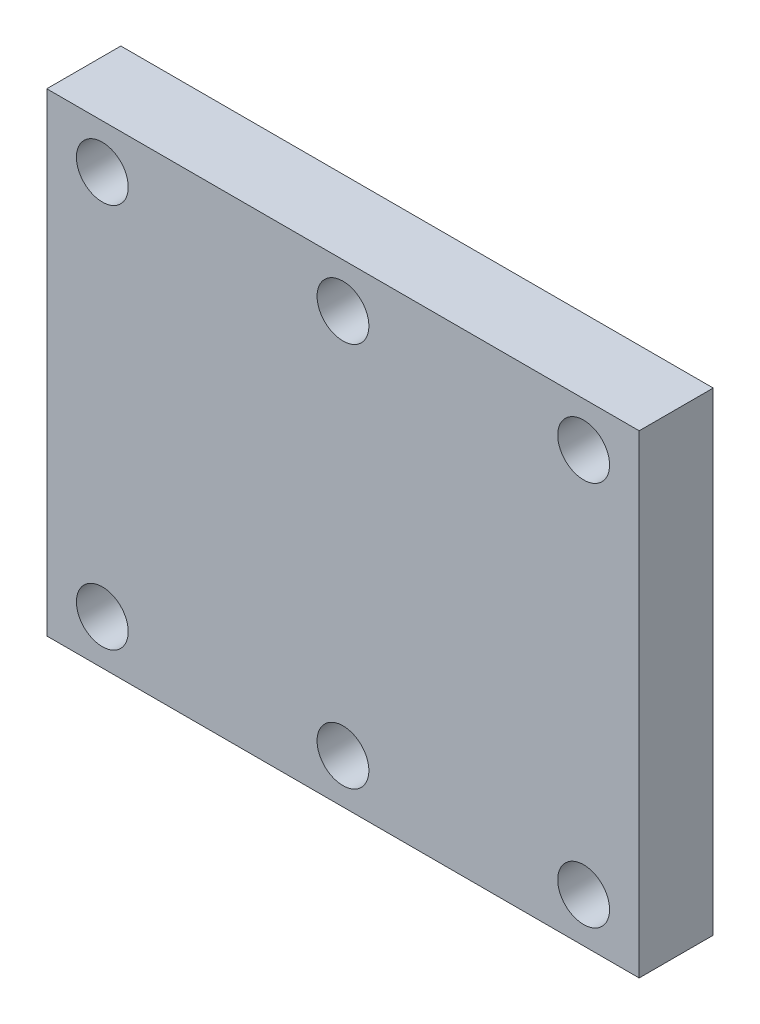
from build123d import *

# Parameters (mm, degrees)
SKETCH1_W            = 80
SKETCH1_H            = 64
BOSS_EXTRUDE1_DEPTH  = 10
LPATTERN1_COUNT      = 3
LPATTERN1_PITCH      = 32.5
LPATTERN1_COUNT_DIR2 = 2
LPATTERN1_PITCH_DIR2 = 52


with BuildPart() as part:
    # Sketch1 → Boss-Extrude1 (new body)
    with BuildSketch(Plane.XY):
        with Locations((40, 0)):
            Rectangle(SKETCH1_W, SKETCH1_H)
    extrude(amount=BOSS_EXTRUDE1_DEPTH)

    # Sketch4 → M6 Clearance Hole1 (revolve, cut)
    with BuildSketch(Plane(origin=(7.5, -26, 10), x_dir=(0, -1, 0), z_dir=(1, 0, 0))):
        Polygon((0, 0), (0, 28.103012167), (3.5, 26), (3.5, 0), align=None)
    m6_clearance_hole1 = revolve(axis=Axis((7.5, -26, 16.35), (0, 0, -1)), mode=Mode.SUBTRACT)

    # LPattern1: M6 Clearance Hole1 3 × 2
    with Locations(*[(i * LPATTERN1_PITCH, j * LPATTERN1_PITCH_DIR2, 0) for i in range(LPATTERN1_COUNT) for j in range(LPATTERN1_COUNT_DIR2) if (i, j) != (0, 0)]):
        add(m6_clearance_hole1, mode=Mode.SUBTRACT)


solid = part.part
